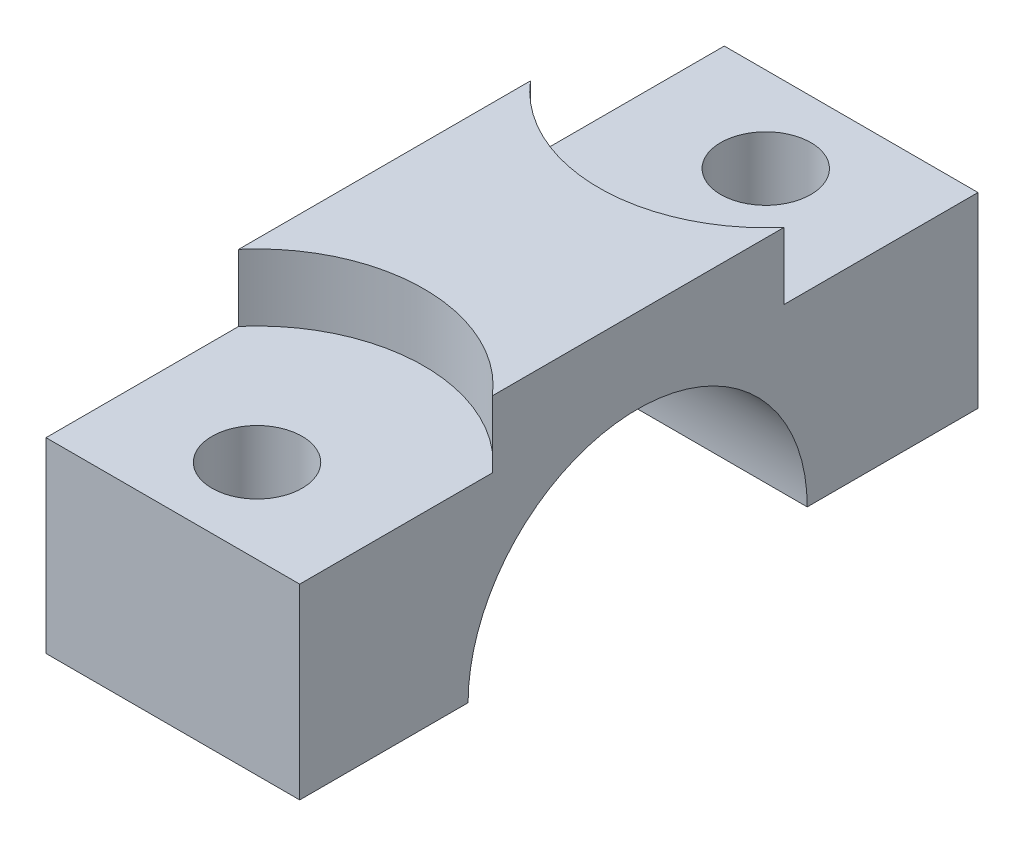
from build123d import *

# Parameters (mm, degrees)
BOSS_EXTRUDE1_DEPTH                           = 19
CBORE_FOR_M12_HEX_HEAD_CAP_SCREW4_D           = 6.75
CBORE_FOR_M12_HEX_HEAD_CAP_SCREW4_CBORE_D     = 25
CBORE_FOR_M12_HEX_HEAD_CAP_SCREW4_CBORE_DEPTH = 5


with BuildPart() as part:
    # Sketch1 → Boss-Extrude1 (new body)
    with BuildSketch(Plane(origin=(0, 0, 0), x_dir=(0, 0, -1), z_dir=(1, 0, 0))):
        with BuildLine():
            ThreePointArc((-12.7, 0), (0, 12.7), (12.7, 0))
            Line((12.7, 0), (25.489438761, 0))
            Line((25.489438761, 0), (25.489438761, 19))
            Line((25.489438761, 19), (-25.310561239, 19))
            Line((-25.310561239, 19), (-25.310561239, 0))
            Line((-25.310561239, 0), (-12.7, 0))
        make_face()
    extrude(amount=BOSS_EXTRUDE1_DEPTH)

    # CBORE for M12 Hex Head Cap Screw4 (through all)
    with Locations(Plane(origin=(0, 19, 0), x_dir=(1, 0, 0), z_dir=(0, 1, 0))):
        with Locations((9.5, 19.094719381), (9.5, -19.005280619)):
            CounterBoreHole(CBORE_FOR_M12_HEX_HEAD_CAP_SCREW4_D / 2, CBORE_FOR_M12_HEX_HEAD_CAP_SCREW4_CBORE_D / 2, CBORE_FOR_M12_HEX_HEAD_CAP_SCREW4_CBORE_DEPTH)


solid = part.part
